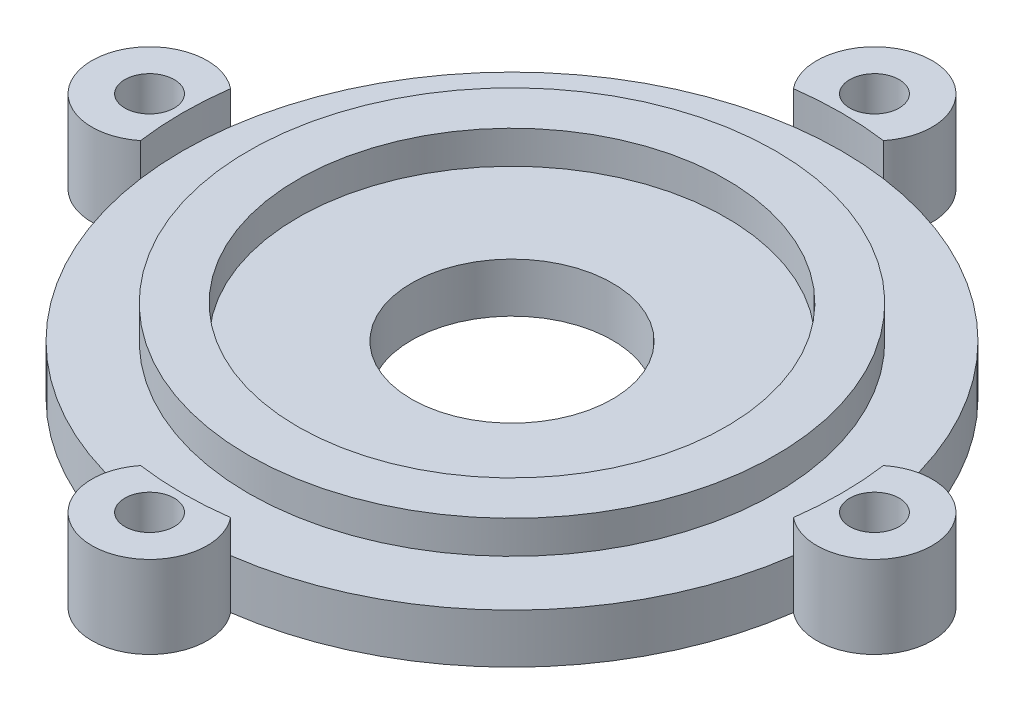
from build123d import *

# Parameters (mm, degrees)
SKETCH1_R           = 1.5
BOSS_EXTRUDE1_DEPTH = 3
BOSS_EXTRUDE2_START = 3
SKETCH1_4_R         = 1.5
SKETCH1_4_R_2       = 16
SKETCH1_4_R_3       = 13
BOSS_EXTRUDE2_DEPTH = 2
SKETCH1_5_R         = 6.1
CUT_EXTRUDE1_DEPTH  = 10


with BuildPart() as part:
    # Sketch1 → Boss-Extrude1 (new body)
    with BuildSketch(Plane(origin=(0, 0, 0), x_dir=(1, 0, 0), z_dir=(0, 1, 0))):
        with BuildLine():
            ThreePointArc((19.8125, 2.732186624), (14.142135624, 14.142135624), (2.732186624, 19.8125))
            ThreePointArc((2.732186624, 19.8125), (0, 25.5), (-2.732186624, 19.8125))
            ThreePointArc((-2.732186624, 19.8125), (-14.142135624, 14.142135624), (-19.8125, 2.732186624))
            ThreePointArc((-19.8125, 2.732186624), (-25.5, 0), (-19.8125, -2.732186624))
            ThreePointArc((-19.8125, -2.732186624), (-14.142135624, -14.142135624), (-2.732186624, -19.8125))
            ThreePointArc((-2.732186624, -19.8125), (0, -25.5), (2.732186624, -19.8125))
            ThreePointArc((2.732186624, -19.8125), (14.142135624, -14.142135624), (19.8125, -2.732186624))
            ThreePointArc((19.8125, -2.732186624), (25.5, 0), (19.8125, 2.732186624))
        make_face()
        with Locations((22, 0)):
            Circle(SKETCH1_R, mode=Mode.SUBTRACT)
        with Locations((0, 22)):
            Circle(SKETCH1_R, mode=Mode.SUBTRACT)
        with Locations((0, -22)):
            Circle(SKETCH1_R, mode=Mode.SUBTRACT)
        with Locations((-22, 0)):
            Circle(SKETCH1_R, mode=Mode.SUBTRACT)
    extrude(amount=BOSS_EXTRUDE1_DEPTH)

    # Sketch1_4 → Boss-Extrude2 (add)
    with BuildSketch(Plane(origin=(0, 0, 0), x_dir=(1, 0, 0), z_dir=(0, 1, 0)).offset(BOSS_EXTRUDE2_START)):
        with BuildLine():
            ThreePointArc((-2.732186624, -19.8125), (0, -25.5), (2.732186624, -19.8125))
            ThreePointArc((2.732186624, -19.8125), (0, -20), (-2.732186624, -19.8125))
        make_face()
        with Locations((0, -22)):
            Circle(SKETCH1_4_R, mode=Mode.SUBTRACT)
        with BuildLine():
            ThreePointArc((19.8125, 2.732186624), (19.953069939, 1.369306394), (20, 0))
            ThreePointArc((20, 0), (19.953069939, -1.369306394), (19.8125, -2.732186624))
            ThreePointArc((19.8125, -2.732186624), (25.5, 0), (19.8125, 2.732186624))
        make_face()
        with Locations((22, 0)):
            Circle(SKETCH1_4_R, mode=Mode.SUBTRACT)
        with BuildLine():
            ThreePointArc((-2.732186624, 19.8125), (0, 20), (2.732186624, 19.8125))
            ThreePointArc((2.732186624, 19.8125), (0, 25.5), (-2.732186624, 19.8125))
        make_face()
        with Locations((0, 22)):
            Circle(SKETCH1_4_R, mode=Mode.SUBTRACT)
        with BuildLine():
            ThreePointArc((-19.8125, -2.732186624), (-20, 0), (-19.8125, 2.732186624))
            ThreePointArc((-19.8125, 2.732186624), (-25.5, 0), (-19.8125, -2.732186624))
        make_face()
        with Locations((-22, 0)):
            Circle(SKETCH1_4_R, mode=Mode.SUBTRACT)
        Circle(SKETCH1_4_R_2)
        Circle(SKETCH1_4_R_3, mode=Mode.SUBTRACT)
    extrude(amount=BOSS_EXTRUDE2_DEPTH)

    # Sketch1_5 → Cut-Extrude1 (cut)
    with BuildSketch(Plane(origin=(0, 0, 0), x_dir=(1, 0, 0), z_dir=(0, 1, 0))):
        Circle(SKETCH1_5_R)
    extrude(amount=CUT_EXTRUDE1_DEPTH, mode=Mode.SUBTRACT)


solid = part.part
